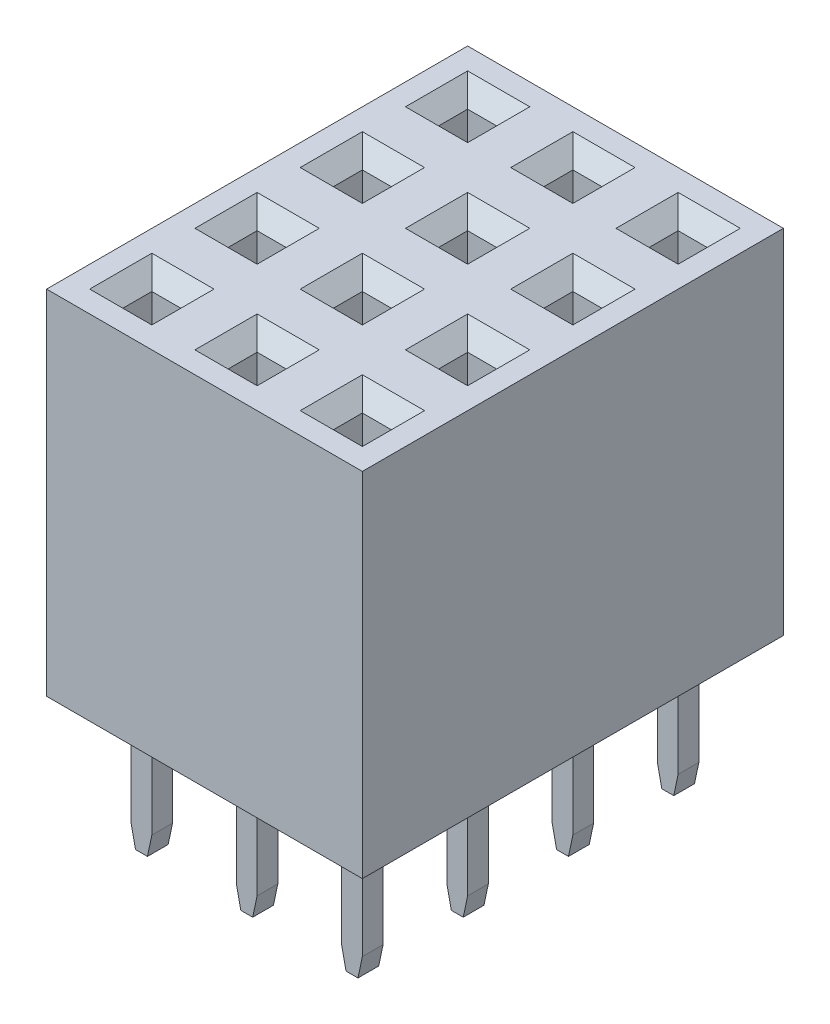
from build123d import *
from OCP.BRepFilletAPI import BRepFilletAPI_MakeChamfer

# Parameters (mm, degrees)
SKETCH_1_W                          = 2.54
SKETCH_1_H                          = 2.54
EXTRUDE_1_DEPTH                     = 8.51
SKETCH_4_W                          = 0.7
SKETCH_4_H                          = 0.7
CUT_EXTRUDE_1_DEPTH                 = 8.21
CHAMFER_3_SIZE                      = 0.4
SKETCH_2_W                          = 0.5
SKETCH_2_H                          = 0.5
EXTRUDE_2_DEPTH                     = 3.15
CHAMFER_2_SIZE                      = 0.5
CHAMFER_2_SIZE2                     = 0.106278281
PATTERN_LINEAR_1_COUNT              = 4
PATTERN_LINEAR_1_PITCH              = 2.54
PATTERN_LINEAR_1_COUNT_DIR2         = 3
PATTERN_LINEAR_1_PITCH_DIR2         = 2.54
CHAMFER_3_OF_PATTERN_LINEAR_1_SIZE  = 0.4
CHAMFER_2_OF_PATTERN_LINEAR_1_SIZE  = 0.5
CHAMFER_2_OF_PATTERN_LINEAR_1_SIZE2 = 0.106278281


with BuildPart() as part:
    # Эскиз1 → Бобышка-Вытянуть1 (new body)
    with BuildSketch(Plane(origin=(0, 0, 0), x_dir=(-1, 0, 0), z_dir=(0, 1, 0))):
        Rectangle(SKETCH_1_W, SKETCH_1_H)
    extrude_1 = extrude(amount=EXTRUDE_1_DEPTH)

    # Эскиз4 → Вырез-Вытянуть1 (cut)
    with BuildSketch(Plane(origin=(0, 8.51, 0), x_dir=(1, 0, 0), z_dir=(0, 1, 0))):
        Rectangle(SKETCH_4_W, SKETCH_4_H)
    cut_extrude_1 = extrude(amount=-CUT_EXTRUDE_1_DEPTH, mode=Mode.SUBTRACT)

    # Фаска3
    chamfer_3_edges = [part.edges().sort_by_distance(p)[0] for p in [
        (-0.35, 8.51, 0),
        (0, 8.51, 0.35),
        (0.35, 8.51, 0),
        (0, 8.51, -0.35),
    ]]
    chamfer(chamfer_3_edges, length=CHAMFER_3_SIZE)

    # Эскиз2 → Бобышка-Вытянуть2 (add)
    with BuildSketch(Plane(origin=(0, 0, 0), x_dir=(-1, 0, 0), z_dir=(0, 1, 0))):
        Rectangle(SKETCH_2_W, SKETCH_2_H)
    extrude_2 = extrude(amount=-EXTRUDE_2_DEPTH)

    # Фаска2: one chamfer whose edges measure the first distance from different faces: ONE call of the kernel's chamfer builder (chamfer() names one face for all edges)
    chamfer_2_edges_1 = [part.edges().sort_by_distance(p)[0] for p in [
        (-0.25, -3.15, 0),
    ]]
    chamfer_2_side_1 = [part.faces().sort_by_distance(p)[0] for p in [
        (-0.25, -1.575, 0),
    ]]
    chamfer_2_edges_2 = [part.edges().sort_by_distance(p)[0] for p in [
        (0.25, -3.15, 0),
    ]]
    chamfer_2_side_2 = [part.faces().sort_by_distance(p)[0] for p in [
        (0.25, -1.575, 0),
    ]]
    chamfer_2 = BRepFilletAPI_MakeChamfer(part.part.solid().wrapped)
    for e in chamfer_2_edges_1:
        chamfer_2.Add(CHAMFER_2_SIZE, CHAMFER_2_SIZE2, e.wrapped, chamfer_2_side_1[0].wrapped)  # the first distance lies on this face
    for e in chamfer_2_edges_2:
        chamfer_2.Add(CHAMFER_2_SIZE, CHAMFER_2_SIZE2, e.wrapped, chamfer_2_side_2[0].wrapped)  # the first distance lies on this face
    add(Compound.cast(chamfer_2.Shape()), mode=Mode.REPLACE)

    # Линейный массив1: Бобышка-Вытянуть1, Вырез-Вытянуть1, Extrude 2 4 × 3
    with Locations(*[(-j * PATTERN_LINEAR_1_PITCH_DIR2, 0, -i * PATTERN_LINEAR_1_PITCH) for i in range(PATTERN_LINEAR_1_COUNT) for j in range(PATTERN_LINEAR_1_COUNT_DIR2) if (i, j) != (0, 0)]):
        add(extrude_1)
        add(cut_extrude_1, mode=Mode.SUBTRACT)
        add(extrude_2)

    # Фаска3 of Линейный массив1
    chamfer_3_of_pattern_linear_1_edges = [part.edges().sort_by_distance(p)[0] for p in [
        (-2.89, 8.51, 0),
        (-2.54, 8.51, 0.35),
        (-2.19, 8.51, 0),
        (-2.54, 8.51, -0.35),
        (-5.43, 8.51, 0),
        (-5.08, 8.51, 0.35),
        (-4.73, 8.51, 0),
        (-5.08, 8.51, -0.35),
        (-0.35, 8.51, -2.54),
        (0, 8.51, -2.19),
        (0.35, 8.51, -2.54),
        (0, 8.51, -2.89),
        (-2.89, 8.51, -2.54),
        (-2.54, 8.51, -2.19),
        (-2.19, 8.51, -2.54),
        (-2.54, 8.51, -2.89),
        (-5.43, 8.51, -2.54),
        (-5.08, 8.51, -2.19),
        (-4.73, 8.51, -2.54),
        (-5.08, 8.51, -2.89),
        (-0.35, 8.51, -5.08),
        (0, 8.51, -4.73),
        (0.35, 8.51, -5.08),
        (0, 8.51, -5.43),
        (-2.89, 8.51, -5.08),
        (-2.54, 8.51, -4.73),
        (-2.19, 8.51, -5.08),
        (-2.54, 8.51, -5.43),
        (-5.43, 8.51, -5.08),
        (-5.08, 8.51, -4.73),
        (-4.73, 8.51, -5.08),
        (-5.08, 8.51, -5.43),
        (-0.35, 8.51, -7.62),
        (0, 8.51, -7.27),
        (0.35, 8.51, -7.62),
        (0, 8.51, -7.97),
        (-2.89, 8.51, -7.62),
        (-2.54, 8.51, -7.27),
        (-2.19, 8.51, -7.62),
        (-2.54, 8.51, -7.97),
        (-5.43, 8.51, -7.62),
        (-5.08, 8.51, -7.27),
        (-4.73, 8.51, -7.62),
        (-5.08, 8.51, -7.97),
    ]]
    chamfer(chamfer_3_of_pattern_linear_1_edges, length=CHAMFER_3_OF_PATTERN_LINEAR_1_SIZE)

    # Фаска2 of Линейный массив1: one chamfer whose edges measure the first distance from different faces: ONE call of the kernel's chamfer builder (chamfer() names one face for all edges)
    chamfer_2_of_pattern_linear_1_edges_1 = [part.edges().sort_by_distance(p)[0] for p in [
        (-2.79, -3.15, 0),
    ]]
    chamfer_2_of_pattern_linear_1_side_1 = [part.faces().sort_by_distance(p)[0] for p in [
        (-2.79, -1.575, 0),
    ]]
    chamfer_2_of_pattern_linear_1_edges_2 = [part.edges().sort_by_distance(p)[0] for p in [
        (-2.29, -3.15, 0),
    ]]
    chamfer_2_of_pattern_linear_1_side_2 = [part.faces().sort_by_distance(p)[0] for p in [
        (-2.29, -1.575, 0),
    ]]
    chamfer_2_of_pattern_linear_1_edges_3 = [part.edges().sort_by_distance(p)[0] for p in [
        (-5.33, -3.15, 0),
    ]]
    chamfer_2_of_pattern_linear_1_side_3 = [part.faces().sort_by_distance(p)[0] for p in [
        (-5.33, -1.575, 0),
    ]]
    chamfer_2_of_pattern_linear_1_edges_4 = [part.edges().sort_by_distance(p)[0] for p in [
        (-4.83, -3.15, 0),
    ]]
    chamfer_2_of_pattern_linear_1_side_4 = [part.faces().sort_by_distance(p)[0] for p in [
        (-4.83, -1.575, 0),
    ]]
    chamfer_2_of_pattern_linear_1_edges_5 = [part.edges().sort_by_distance(p)[0] for p in [
        (-0.25, -3.15, -2.54),
    ]]
    chamfer_2_of_pattern_linear_1_side_5 = [part.faces().sort_by_distance(p)[0] for p in [
        (-0.25, -1.575, -2.54),
    ]]
    chamfer_2_of_pattern_linear_1_edges_6 = [part.edges().sort_by_distance(p)[0] for p in [
        (0.25, -3.15, -2.54),
    ]]
    chamfer_2_of_pattern_linear_1_side_6 = [part.faces().sort_by_distance(p)[0] for p in [
        (0.25, -1.575, -2.54),
    ]]
    chamfer_2_of_pattern_linear_1_edges_7 = [part.edges().sort_by_distance(p)[0] for p in [
        (-2.79, -3.15, -2.54),
    ]]
    chamfer_2_of_pattern_linear_1_side_7 = [part.faces().sort_by_distance(p)[0] for p in [
        (-2.79, -1.575, -2.54),
    ]]
    chamfer_2_of_pattern_linear_1_edges_8 = [part.edges().sort_by_distance(p)[0] for p in [
        (-2.29, -3.15, -2.54),
    ]]
    chamfer_2_of_pattern_linear_1_side_8 = [part.faces().sort_by_distance(p)[0] for p in [
        (-2.29, -1.575, -2.54),
    ]]
    chamfer_2_of_pattern_linear_1_edges_9 = [part.edges().sort_by_distance(p)[0] for p in [
        (-5.33, -3.15, -2.54),
    ]]
    chamfer_2_of_pattern_linear_1_side_9 = [part.faces().sort_by_distance(p)[0] for p in [
        (-5.33, -1.575, -2.54),
    ]]
    chamfer_2_of_pattern_linear_1_edges_10 = [part.edges().sort_by_distance(p)[0] for p in [
        (-4.83, -3.15, -2.54),
    ]]
    chamfer_2_of_pattern_linear_1_side_10 = [part.faces().sort_by_distance(p)[0] for p in [
        (-4.83, -1.575, -2.54),
    ]]
    chamfer_2_of_pattern_linear_1_edges_11 = [part.edges().sort_by_distance(p)[0] for p in [
        (-0.25, -3.15, -5.08),
    ]]
    chamfer_2_of_pattern_linear_1_side_11 = [part.faces().sort_by_distance(p)[0] for p in [
        (-0.25, -1.575, -5.08),
    ]]
    chamfer_2_of_pattern_linear_1_edges_12 = [part.edges().sort_by_distance(p)[0] for p in [
        (0.25, -3.15, -5.08),
    ]]
    chamfer_2_of_pattern_linear_1_side_12 = [part.faces().sort_by_distance(p)[0] for p in [
        (0.25, -1.575, -5.08),
    ]]
    chamfer_2_of_pattern_linear_1_edges_13 = [part.edges().sort_by_distance(p)[0] for p in [
        (-2.79, -3.15, -5.08),
    ]]
    chamfer_2_of_pattern_linear_1_side_13 = [part.faces().sort_by_distance(p)[0] for p in [
        (-2.79, -1.575, -5.08),
    ]]
    chamfer_2_of_pattern_linear_1_edges_14 = [part.edges().sort_by_distance(p)[0] for p in [
        (-2.29, -3.15, -5.08),
    ]]
    chamfer_2_of_pattern_linear_1_side_14 = [part.faces().sort_by_distance(p)[0] for p in [
        (-2.29, -1.575, -5.08),
    ]]
    chamfer_2_of_pattern_linear_1_edges_15 = [part.edges().sort_by_distance(p)[0] for p in [
        (-5.33, -3.15, -5.08),
    ]]
    chamfer_2_of_pattern_linear_1_side_15 = [part.faces().sort_by_distance(p)[0] for p in [
        (-5.33, -1.575, -5.08),
    ]]
    chamfer_2_of_pattern_linear_1_edges_16 = [part.edges().sort_by_distance(p)[0] for p in [
        (-4.83, -3.15, -5.08),
    ]]
    chamfer_2_of_pattern_linear_1_side_16 = [part.faces().sort_by_distance(p)[0] for p in [
        (-4.83, -1.575, -5.08),
    ]]
    chamfer_2_of_pattern_linear_1_edges_17 = [part.edges().sort_by_distance(p)[0] for p in [
        (-0.25, -3.15, -7.62),
    ]]
    chamfer_2_of_pattern_linear_1_side_17 = [part.faces().sort_by_distance(p)[0] for p in [
        (-0.25, -1.575, -7.62),
    ]]
    chamfer_2_of_pattern_linear_1_edges_18 = [part.edges().sort_by_distance(p)[0] for p in [
        (0.25, -3.15, -7.62),
    ]]
    chamfer_2_of_pattern_linear_1_side_18 = [part.faces().sort_by_distance(p)[0] for p in [
        (0.25, -1.575, -7.62),
    ]]
    chamfer_2_of_pattern_linear_1_edges_19 = [part.edges().sort_by_distance(p)[0] for p in [
        (-2.79, -3.15, -7.62),
    ]]
    chamfer_2_of_pattern_linear_1_side_19 = [part.faces().sort_by_distance(p)[0] for p in [
        (-2.79, -1.575, -7.62),
    ]]
    chamfer_2_of_pattern_linear_1_edges_20 = [part.edges().sort_by_distance(p)[0] for p in [
        (-2.29, -3.15, -7.62),
    ]]
    chamfer_2_of_pattern_linear_1_side_20 = [part.faces().sort_by_distance(p)[0] for p in [
        (-2.29, -1.575, -7.62),
    ]]
    chamfer_2_of_pattern_linear_1_edges_21 = [part.edges().sort_by_distance(p)[0] for p in [
        (-5.33, -3.15, -7.62),
    ]]
    chamfer_2_of_pattern_linear_1_side_21 = [part.faces().sort_by_distance(p)[0] for p in [
        (-5.33, -1.575, -7.62),
    ]]
    chamfer_2_of_pattern_linear_1_edges_22 = [part.edges().sort_by_distance(p)[0] for p in [
        (-4.83, -3.15, -7.62),
    ]]
    chamfer_2_of_pattern_linear_1_side_22 = [part.faces().sort_by_distance(p)[0] for p in [
        (-4.83, -1.575, -7.62),
    ]]
    chamfer_2_of_pattern_linear_1 = BRepFilletAPI_MakeChamfer(part.part.solid().wrapped)
    for e in chamfer_2_of_pattern_linear_1_edges_1:
        chamfer_2_of_pattern_linear_1.Add(CHAMFER_2_OF_PATTERN_LINEAR_1_SIZE, CHAMFER_2_OF_PATTERN_LINEAR_1_SIZE2, e.wrapped, chamfer_2_of_pattern_linear_1_side_1[0].wrapped)  # the first distance lies on this face
    for e in chamfer_2_of_pattern_linear_1_edges_2:
        chamfer_2_of_pattern_linear_1.Add(CHAMFER_2_OF_PATTERN_LINEAR_1_SIZE, CHAMFER_2_OF_PATTERN_LINEAR_1_SIZE2, e.wrapped, chamfer_2_of_pattern_linear_1_side_2[0].wrapped)  # the first distance lies on this face
    for e in chamfer_2_of_pattern_linear_1_edges_3:
        chamfer_2_of_pattern_linear_1.Add(CHAMFER_2_OF_PATTERN_LINEAR_1_SIZE, CHAMFER_2_OF_PATTERN_LINEAR_1_SIZE2, e.wrapped, chamfer_2_of_pattern_linear_1_side_3[0].wrapped)  # the first distance lies on this face
    for e in chamfer_2_of_pattern_linear_1_edges_4:
        chamfer_2_of_pattern_linear_1.Add(CHAMFER_2_OF_PATTERN_LINEAR_1_SIZE, CHAMFER_2_OF_PATTERN_LINEAR_1_SIZE2, e.wrapped, chamfer_2_of_pattern_linear_1_side_4[0].wrapped)  # the first distance lies on this face
    for e in chamfer_2_of_pattern_linear_1_edges_5:
        chamfer_2_of_pattern_linear_1.Add(CHAMFER_2_OF_PATTERN_LINEAR_1_SIZE, CHAMFER_2_OF_PATTERN_LINEAR_1_SIZE2, e.wrapped, chamfer_2_of_pattern_linear_1_side_5[0].wrapped)  # the first distance lies on this face
    for e in chamfer_2_of_pattern_linear_1_edges_6:
        chamfer_2_of_pattern_linear_1.Add(CHAMFER_2_OF_PATTERN_LINEAR_1_SIZE, CHAMFER_2_OF_PATTERN_LINEAR_1_SIZE2, e.wrapped, chamfer_2_of_pattern_linear_1_side_6[0].wrapped)  # the first distance lies on this face
    for e in chamfer_2_of_pattern_linear_1_edges_7:
        chamfer_2_of_pattern_linear_1.Add(CHAMFER_2_OF_PATTERN_LINEAR_1_SIZE, CHAMFER_2_OF_PATTERN_LINEAR_1_SIZE2, e.wrapped, chamfer_2_of_pattern_linear_1_side_7[0].wrapped)  # the first distance lies on this face
    for e in chamfer_2_of_pattern_linear_1_edges_8:
        chamfer_2_of_pattern_linear_1.Add(CHAMFER_2_OF_PATTERN_LINEAR_1_SIZE, CHAMFER_2_OF_PATTERN_LINEAR_1_SIZE2, e.wrapped, chamfer_2_of_pattern_linear_1_side_8[0].wrapped)  # the first distance lies on this face
    for e in chamfer_2_of_pattern_linear_1_edges_9:
        chamfer_2_of_pattern_linear_1.Add(CHAMFER_2_OF_PATTERN_LINEAR_1_SIZE, CHAMFER_2_OF_PATTERN_LINEAR_1_SIZE2, e.wrapped, chamfer_2_of_pattern_linear_1_side_9[0].wrapped)  # the first distance lies on this face
    for e in chamfer_2_of_pattern_linear_1_edges_10:
        chamfer_2_of_pattern_linear_1.Add(CHAMFER_2_OF_PATTERN_LINEAR_1_SIZE, CHAMFER_2_OF_PATTERN_LINEAR_1_SIZE2, e.wrapped, chamfer_2_of_pattern_linear_1_side_10[0].wrapped)  # the first distance lies on this face
    for e in chamfer_2_of_pattern_linear_1_edges_11:
        chamfer_2_of_pattern_linear_1.Add(CHAMFER_2_OF_PATTERN_LINEAR_1_SIZE, CHAMFER_2_OF_PATTERN_LINEAR_1_SIZE2, e.wrapped, chamfer_2_of_pattern_linear_1_side_11[0].wrapped)  # the first distance lies on this face
    for e in chamfer_2_of_pattern_linear_1_edges_12:
        chamfer_2_of_pattern_linear_1.Add(CHAMFER_2_OF_PATTERN_LINEAR_1_SIZE, CHAMFER_2_OF_PATTERN_LINEAR_1_SIZE2, e.wrapped, chamfer_2_of_pattern_linear_1_side_12[0].wrapped)  # the first distance lies on this face
    for e in chamfer_2_of_pattern_linear_1_edges_13:
        chamfer_2_of_pattern_linear_1.Add(CHAMFER_2_OF_PATTERN_LINEAR_1_SIZE, CHAMFER_2_OF_PATTERN_LINEAR_1_SIZE2, e.wrapped, chamfer_2_of_pattern_linear_1_side_13[0].wrapped)  # the first distance lies on this face
    for e in chamfer_2_of_pattern_linear_1_edges_14:
        chamfer_2_of_pattern_linear_1.Add(CHAMFER_2_OF_PATTERN_LINEAR_1_SIZE, CHAMFER_2_OF_PATTERN_LINEAR_1_SIZE2, e.wrapped, chamfer_2_of_pattern_linear_1_side_14[0].wrapped)  # the first distance lies on this face
    for e in chamfer_2_of_pattern_linear_1_edges_15:
        chamfer_2_of_pattern_linear_1.Add(CHAMFER_2_OF_PATTERN_LINEAR_1_SIZE, CHAMFER_2_OF_PATTERN_LINEAR_1_SIZE2, e.wrapped, chamfer_2_of_pattern_linear_1_side_15[0].wrapped)  # the first distance lies on this face
    for e in chamfer_2_of_pattern_linear_1_edges_16:
        chamfer_2_of_pattern_linear_1.Add(CHAMFER_2_OF_PATTERN_LINEAR_1_SIZE, CHAMFER_2_OF_PATTERN_LINEAR_1_SIZE2, e.wrapped, chamfer_2_of_pattern_linear_1_side_16[0].wrapped)  # the first distance lies on this face
    for e in chamfer_2_of_pattern_linear_1_edges_17:
        chamfer_2_of_pattern_linear_1.Add(CHAMFER_2_OF_PATTERN_LINEAR_1_SIZE, CHAMFER_2_OF_PATTERN_LINEAR_1_SIZE2, e.wrapped, chamfer_2_of_pattern_linear_1_side_17[0].wrapped)  # the first distance lies on this face
    for e in chamfer_2_of_pattern_linear_1_edges_18:
        chamfer_2_of_pattern_linear_1.Add(CHAMFER_2_OF_PATTERN_LINEAR_1_SIZE, CHAMFER_2_OF_PATTERN_LINEAR_1_SIZE2, e.wrapped, chamfer_2_of_pattern_linear_1_side_18[0].wrapped)  # the first distance lies on this face
    for e in chamfer_2_of_pattern_linear_1_edges_19:
        chamfer_2_of_pattern_linear_1.Add(CHAMFER_2_OF_PATTERN_LINEAR_1_SIZE, CHAMFER_2_OF_PATTERN_LINEAR_1_SIZE2, e.wrapped, chamfer_2_of_pattern_linear_1_side_19[0].wrapped)  # the first distance lies on this face
    for e in chamfer_2_of_pattern_linear_1_edges_20:
        chamfer_2_of_pattern_linear_1.Add(CHAMFER_2_OF_PATTERN_LINEAR_1_SIZE, CHAMFER_2_OF_PATTERN_LINEAR_1_SIZE2, e.wrapped, chamfer_2_of_pattern_linear_1_side_20[0].wrapped)  # the first distance lies on this face
    for e in chamfer_2_of_pattern_linear_1_edges_21:
        chamfer_2_of_pattern_linear_1.Add(CHAMFER_2_OF_PATTERN_LINEAR_1_SIZE, CHAMFER_2_OF_PATTERN_LINEAR_1_SIZE2, e.wrapped, chamfer_2_of_pattern_linear_1_side_21[0].wrapped)  # the first distance lies on this face
    for e in chamfer_2_of_pattern_linear_1_edges_22:
        chamfer_2_of_pattern_linear_1.Add(CHAMFER_2_OF_PATTERN_LINEAR_1_SIZE, CHAMFER_2_OF_PATTERN_LINEAR_1_SIZE2, e.wrapped, chamfer_2_of_pattern_linear_1_side_22[0].wrapped)  # the first distance lies on this face
    add(Compound.cast(chamfer_2_of_pattern_linear_1.Shape()), mode=Mode.REPLACE)


solid = part.part
